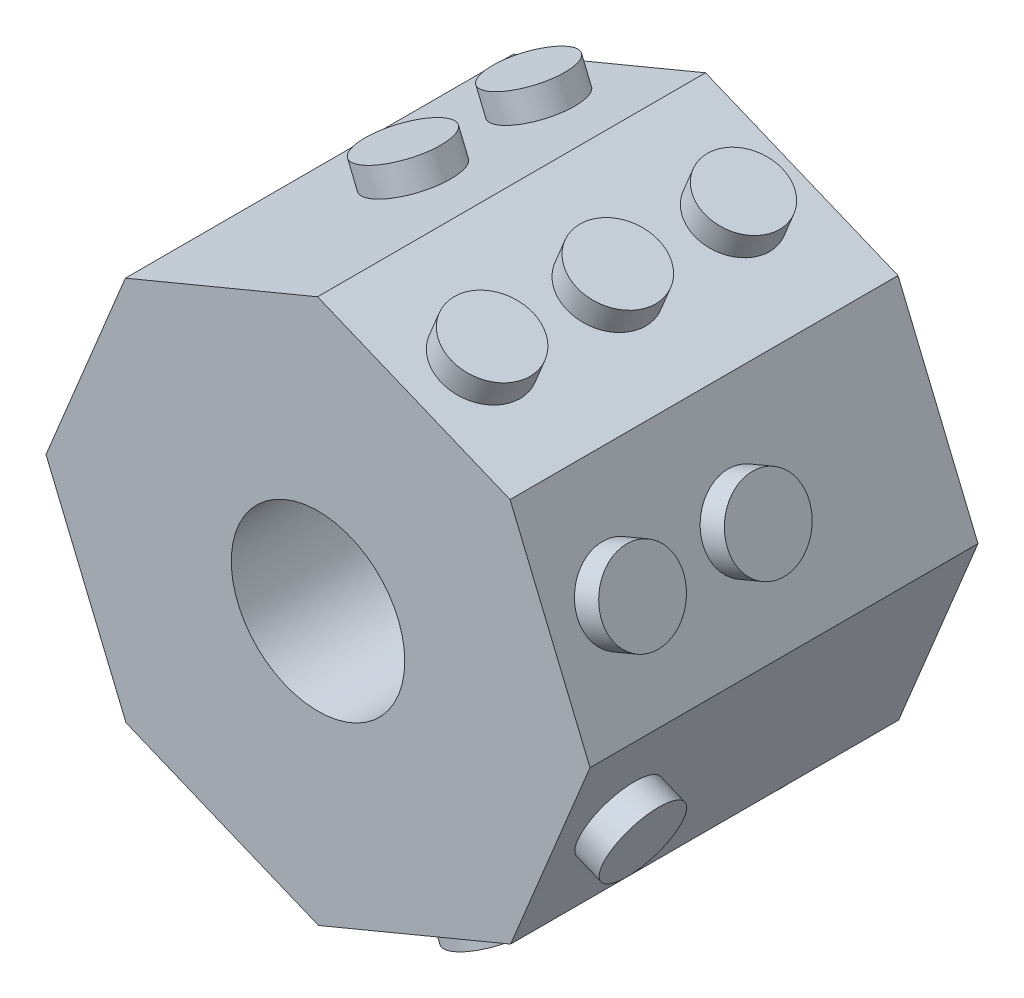
from build123d import *

# Parameters (mm, degrees)
BOSS_EXTRUDE1_DEPTH  = 7.1
SKETCH2_R            = 0.714611453
SKETCH2_R_2          = 0.75
BOSS_EXTRUDE2_DEPTH  = 0.48
SKETCH8_R            = 0.75
BOSS_EXTRUDE4_DEPTH  = 0.48
SKETCH9_R            = 0.75
BOSS_EXTRUDE5_DEPTH  = 0.48
SKETCH10_R           = 0.714611453
SKETCH10_R_2         = 0.75
BOSS_EXTRUDE7_DEPTH  = 0.48
SKETCH11_R           = 0.714611453
SKETCH11_R_2         = 0.75
BOSS_EXTRUDE8_DEPTH  = 0.48
SKETCH12_R           = 0.714611453
BOSS_EXTRUDE9_DEPTH  = 0.48
SKETCH13_R           = 0.75
BOSS_EXTRUDE10_DEPTH = 0.48
SKETCH15_R           = 1.5875
CUT_EXTRUDE3_DEPTH   = 8.1


with BuildPart() as part:
    # Sketch1 → Boss-Extrude1 (new body)
    with BuildSketch(Plane.XY):
        Polygon((-0.007801135, 4.977998784), (-3.525492932, 3.514460461), (-4.977998784, -0.007801135), (-3.514460461, -3.525492932), (0.007801135, -4.977998784), (3.525492932, -3.514460461), (4.977998784, 0.007801135), (3.514460461, 3.525492932), align=None)
    extrude(amount=BOSS_EXTRUDE1_DEPTH)

    # Sketch2 → Boss-Extrude2 (add)
    with BuildSketch(Plane(origin=(1.753329663, 4.251745858, 0), x_dir=(0.924478109, -0.381235132, 0), z_dir=(0.381235132, 0.924478109, 0))):
        with Locations((0, -1.25)):
            Circle(SKETCH2_R)
        with Locations((0, -3.55)):
            Circle(SKETCH2_R_2)
        with Locations((0, -5.85)):
            Circle(SKETCH2_R_2)
    extrude(amount=BOSS_EXTRUDE2_DEPTH)

    # Sketch8 → Boss-Extrude4 (add)
    with BuildSketch(Plane(origin=(4.246229622, 1.766647033, 0), x_dir=(0, 0, -1), z_dir=(0.923278687, 0.384130793, 0))):
        with Locations((-3.55, 0)):
            Circle(SKETCH8_R)
        with Locations((-5.85, 0)):
            Circle(SKETCH8_R)
    extrude(amount=BOSS_EXTRUDE4_DEPTH)

    # Sketch9 → Boss-Extrude5 (add)
    with BuildSketch(Plane(origin=(4.251745858, -1.753329663, 0), x_dir=(0, 0, -1), z_dir=(0.924478109, -0.381235132, 0))):
        with Locations((-5.85, 0)):
            Circle(SKETCH9_R)
    extrude(amount=BOSS_EXTRUDE5_DEPTH)

    # Sketch10 → Boss-Extrude7 (add)
    with BuildSketch(Plane(origin=(1.766647033, -4.246229622, 0), x_dir=(0.923278687, 0.384130793, 0), z_dir=(0.384130793, -0.923278687, 0))):
        with Locations((0, 5.85)):
            Circle(SKETCH10_R)
        with Locations((0, 1.25)):
            Circle(SKETCH10_R_2)
    extrude(amount=BOSS_EXTRUDE7_DEPTH)

    # Sketch11 → Boss-Extrude8 (add)
    with BuildSketch(Plane(origin=(-1.766647033, 4.246229622, 0), x_dir=(0.923278687, 0.384130793, 0), z_dir=(-0.384130793, 0.923278687, 0))):
        with Locations((-0.048036035, -1.25)):
            Circle(SKETCH11_R)
        with Locations((-0.048036035, -3.55)):
            Circle(SKETCH11_R_2)
    extrude(amount=BOSS_EXTRUDE8_DEPTH)

    # Sketch12 → Boss-Extrude9 (add)
    with BuildSketch(Plane(origin=(-4.251745858, 1.753329663, 0), x_dir=(0, 0, 1), z_dir=(-0.924478109, 0.381235132, 0))):
        with Locations((1.25, 0)):
            Circle(SKETCH12_R)
    extrude(amount=BOSS_EXTRUDE9_DEPTH)

    # Sketch13 → Boss-Extrude10 (add)
    with BuildSketch(Plane(origin=(-1.753329663, -4.251745858, 0), x_dir=(0.924478109, -0.381235132, 0), z_dir=(-0.381235132, -0.924478109, 0))):
        with Locations((0, 3.55)):
            Circle(SKETCH13_R)
    extrude(amount=BOSS_EXTRUDE10_DEPTH)

    # Sketch15 → Cut-Extrude3 (cut, through all)
    with BuildSketch(Plane.XY.offset(7.1)):
        Circle(SKETCH15_R)
    extrude(amount=-CUT_EXTRUDE3_DEPTH, mode=Mode.SUBTRACT)


solid = part.part
